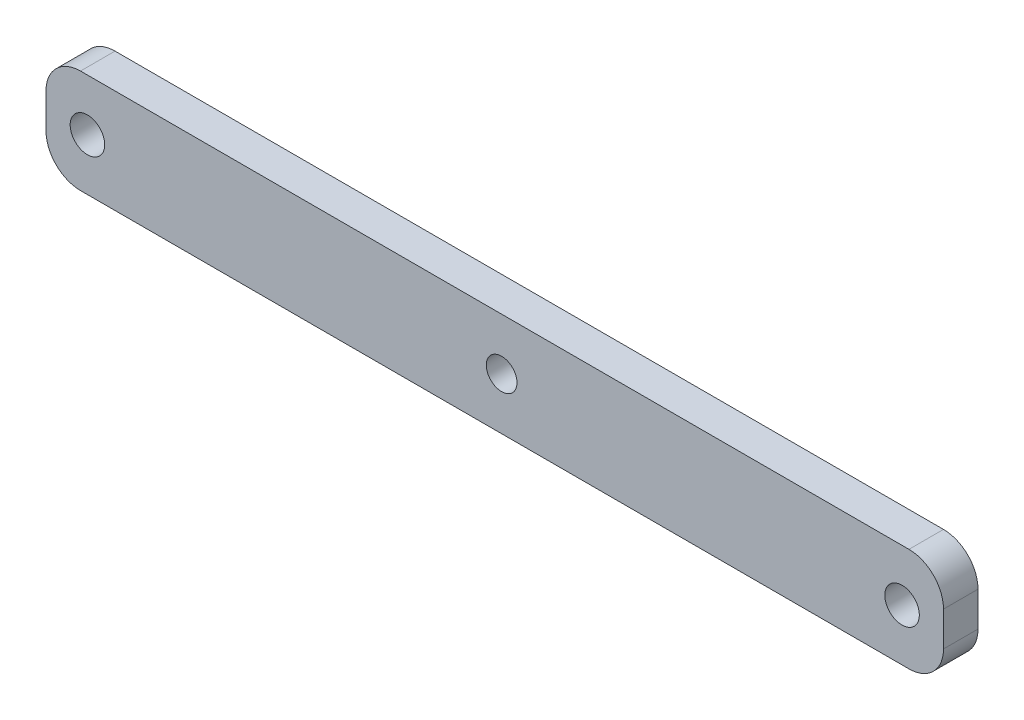
from build123d import *

# Parameters (mm, degrees)
SKETCH20_R          = 2.5
SKETCH20_R_2        = 2.223415724
BOSS_EXTRUDE3_DEPTH = 5


with BuildPart() as part:
    # Sketch20 → Boss-Extrude3 (new body)
    with BuildSketch(Plane.XY):
        with BuildLine():
            Line((-21.986240354, -1.999752434), (98.013759646, -1.999752434))
            ThreePointArc((98.013759646, -1.999752434), (101.549293552, -3.464218528), (103.013759646, -6.999752434))
            Line((103.013759646, -6.999752434), (103.013759646, -11.999752434))
            ThreePointArc((103.013759646, -11.999752434), (101.549293552, -15.53528634), (98.013759646, -16.999752434))
            Line((98.013759646, -16.999752434), (-21.986240354, -16.999752434))
            ThreePointArc((-21.986240354, -16.999752434), (-25.52177426, -15.53528634), (-26.986240354, -11.999752434))
            Line((-26.986240354, -11.999752434), (-26.986240354, -6.999752434))
            ThreePointArc((-26.986240354, -6.999752434), (-25.52177426, -3.464218528), (-21.986240354, -1.999752434))
        make_face()
        with Locations((-20.986240354, -9.499752434)):
            Circle(SKETCH20_R, mode=Mode.SUBTRACT)
        with Locations((97.013759646, -9.499752434)):
            Circle(SKETCH20_R, mode=Mode.SUBTRACT)
        with Locations((39.013759646, -9.499752434)):
            Circle(SKETCH20_R_2, mode=Mode.SUBTRACT)
    extrude(amount=BOSS_EXTRUDE3_DEPTH)


solid = part.part
